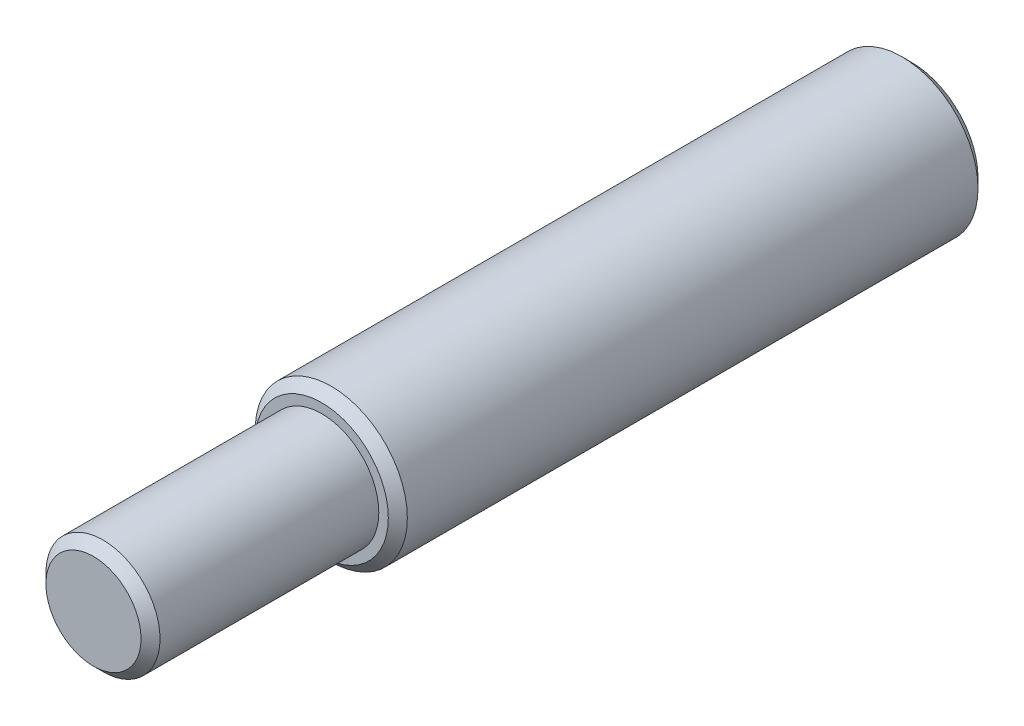
from build123d import *

# Parameters (mm, degrees)
SKETCH_1_R          = 4
EXTRUDE_1_DEPTH     = 10
EXTRUDE_2_DEPTH     = 8
SKETCH_3_R          = 4
EXTRUDE_3_DEPTH     = 13
SKETCH_4_R          = 3
EXTRUDE_4_DEPTH     = 12
CHAMFER_1_SIZE      = 0.5
SKETCH_5_R          = 13.06418711
SKETCH_5_R_2        = 4
CUT_EXTRUDE_1_DEPTH = 10


with BuildPart() as part:
    # 草图1 → 凸台-拉伸1 (new body)
    with BuildSketch(Plane.XY):
        Circle(SKETCH_1_R)
    extrude(amount=EXTRUDE_1_DEPTH)

    # 草图2 → 凸台-拉伸2 (add)
    with BuildSketch(Plane.XY.offset(10)):
        Polygon((10, 0), (5, 8.660254038), (-5, 8.660254038), (-10, 0), (-5, -8.660254038), (5, -8.660254038), align=None)
    extrude(amount=EXTRUDE_2_DEPTH)

    # 草图3 → 凸台-拉伸3 (add)
    with BuildSketch(Plane.XY.offset(18)):
        Circle(SKETCH_3_R)
    extrude(amount=EXTRUDE_3_DEPTH)

    # 草图4 → 凸台-拉伸4 (add)
    with BuildSketch(Plane.XY.offset(31)):
        Circle(SKETCH_4_R)
    extrude(amount=EXTRUDE_4_DEPTH)

    # 倒角1
    chamfer_1_edges = [part.edges().sort_by_distance(p)[0] for p in [
        (-4, 0, 0),
        (-4, 0, 31),
        (-3, 0, 43),
    ]]
    chamfer(chamfer_1_edges, length=CHAMFER_1_SIZE)

    # 草图5 → 切除-拉伸1 (cut)
    with BuildSketch(Plane(origin=(0, 0, 10), x_dir=(-1, 0, 0), z_dir=(0, 0, -1))):
        Circle(SKETCH_5_R)
        Circle(SKETCH_5_R_2, mode=Mode.SUBTRACT)
    extrude(amount=-CUT_EXTRUDE_1_DEPTH, mode=Mode.SUBTRACT)


solid = part.part
